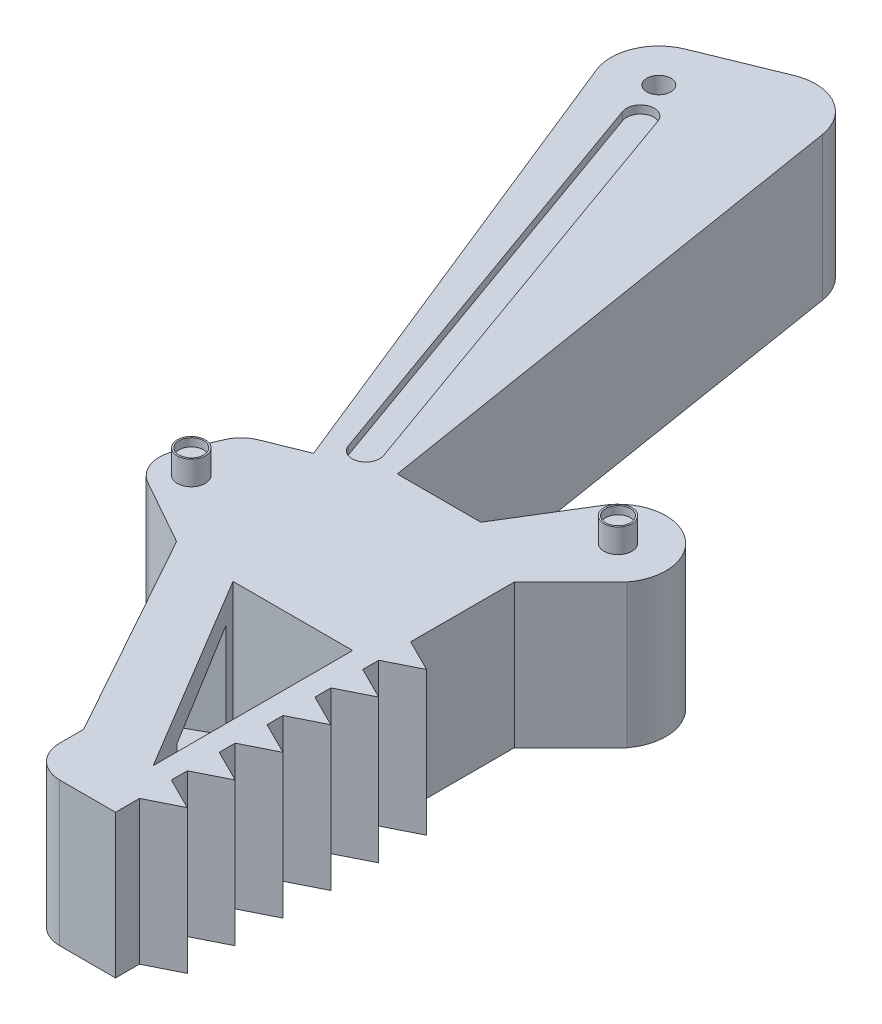
from build123d import *

# Parameters (mm, degrees)
BOSS_EXTRUDE1_DEPTH = 9
FILLET1_R           = 6
FILLET2_R           = 4
BOSS_EXTRUDE2_DEPTH = 18
LPATTERN1_COUNT     = 6
LPATTERN1_PITCH     = 6
CUT_EXTRUDE1_DEPTH  = 19
CUT_EXTRUDE2_DEPTH  = 8
SKETCH5_R           = 1.5
CUT_EXTRUDE3_DEPTH  = 19
SKETCH6_R           = 1.75
BOSS_EXTRUDE3_DEPTH = 3
SKETCH7_R           = 1.55
CUT_EXTRUDE4_DEPTH  = 1
SKETCH8_R           = 1.55
CUT_EXTRUDE5_DEPTH  = 1
CUT_EXTRUDE7_DEPTH  = 1


with BuildPart() as part:
    # Sketch1 → Boss-Extrude1 (new body, symmetric)
    with BuildSketch(Plane(origin=(0, 0, 0), x_dir=(1, 0, 0), z_dir=(0, 1, 0))):
        with BuildLine():
            Line((-12.33246069, -71), (-19.816764537, -74.012394232))
            Line((-19.816764537, -74.012394232), (-26.247607485, -76.600775811))
            Line((-26.247607485, -76.600775811), (-30.167039554, -85.800669955))
            Line((-30.167039554, -85.800669955), (-18.831549927, -92.165155394))
            Line((-18.831549927, -92.165155394), (-4.262261991, -118.389873678))
            Line((-4.262261991, -118.389873678), (-4.262261991, -125.389873678))
            Line((-4.262261991, -125.389873678), (6.737738009, -125.389873678))
            Line((6.737738009, -125.389873678), (6.737738009, -75.389873678))
            Line((6.737738009, -75.389873678), (13.808805821, -68.318805866))
            ThreePointArc((13.808805821, -68.318805866), (12.667091661, -59.910685459), (4.258971254, -61.052399619))
            Line((4.258971254, -61.052399619), (-1.849045895, -71))
            Line((-1.849045895, -71), (-12.33246069, -71))
        make_face()
        Polygon((-12.33246069, -71), (-19.816764537, -74.012394232), (-45.953718322, -9.075042525), (-23.735626524, 0), align=None)
    extrude(amount=BOSS_EXTRUDE1_DEPTH, both=True)

    # Fillet1
    fillet1_edges = [part.edges().sort_by_distance(p)[0] for p in [
        (-45.953718322, 0, 9.075042525),
        (-23.735626524, 0, 0),
    ]]
    fillet(fillet1_edges, radius=FILLET1_R)

    # Fillet2
    fillet2_edges = [part.edges().sort_by_distance(p)[0] for p in [
        (-4.262261991, 0, 125.389873678),
        (-30.167039554, 0, 85.800669955),
        (-26.247607485, 0, 76.600775811),
    ]]
    fillet(fillet2_edges, radius=FILLET2_R)

    # Sketch2 → Boss-Extrude2 (add)
    with BuildSketch(Plane(origin=(0, 9, 0), x_dir=(1, 0, 0), z_dir=(0, 1, 0))):
        Polygon((6.737738009, -118.389873678), (6.737738009, -122.389873678), (10.737738009, -120.389873678), align=None)
    boss_extrude2 = extrude(amount=-BOSS_EXTRUDE2_DEPTH)

    # LPattern1: Boss-Extrude2 ×6
    with Locations(*[(0, 0, -i * LPATTERN1_PITCH) for i in range(1, LPATTERN1_COUNT)]):
        add(boss_extrude2)

    # Sketch3 → Cut-Extrude1 (cut, through all)
    with BuildSketch(Plane(origin=(0, 9, 0), x_dir=(1, 0, 0), z_dir=(0, 1, 0))):
        Polygon((4.039450666, -92.96261283), (-10.960549334, -92.96261283), (4.039450666, -117.96261283), align=None)
    extrude(amount=-CUT_EXTRUDE1_DEPTH, mode=Mode.SUBTRACT)

    # Sketch4 → Cut-Extrude2 (cut)
    with BuildSketch(Plane(origin=(-53.516863555, 0, 29.731590864), x_dir=(0.485642931, 0, 0.874157276), z_dir=(-0.874157276, 0, 0.485642931))):
        Polygon((78.421432088, 6), (78.421432088, -6), (96.421432088, -5.431048589), (96.421432088, 5.431048589), align=None)
    extrude(amount=-CUT_EXTRUDE2_DEPTH, mode=Mode.SUBTRACT)

    # Sketch5 → Cut-Extrude3 (cut, through all)
    with BuildSketch(Plane(origin=(0, 9, 0), x_dir=(1, 0, 0), z_dir=(0, 1, 0))):
        with Locations((-38.158783011, -12.372383774)):
            Circle(SKETCH5_R)
    extrude(amount=-CUT_EXTRUDE3_DEPTH, mode=Mode.SUBTRACT)

    # Sketch6 → Boss-Extrude3 (add)
    with BuildSketch(Plane(origin=(0, 9, 0), x_dir=(1, 0, 0), z_dir=(0, 1, 0))):
        with Locations((-25.081319154, -84.068763596)):
            Circle(SKETCH6_R)
        with Locations((9.033888537, -64.685602742)):
            Circle(SKETCH6_R)
    boss_extrude3 = extrude(amount=BOSS_EXTRUDE3_DEPTH)

    # Sketch7 → Cut-Extrude4 (cut)
    with BuildSketch(Plane(origin=(0, 12, 0), x_dir=(1, 0, 0), z_dir=(0, 1, 0))):
        with Locations((-25.081319154, -84.068763596)):
            Circle(SKETCH7_R)
    cut_extrude4 = extrude(amount=-CUT_EXTRUDE4_DEPTH, mode=Mode.SUBTRACT)

    # Sketch8 → Cut-Extrude5 (cut)
    with BuildSketch(Plane(origin=(0, 12, 0), x_dir=(1, 0, 0), z_dir=(0, 1, 0))):
        with Locations((9.033888537, -64.685602742)):
            Circle(SKETCH8_R)
    cut_extrude5 = extrude(amount=-CUT_EXTRUDE5_DEPTH, mode=Mode.SUBTRACT)

    # Sketch9 → Cut-Extrude7 (cut)
    with BuildSketch(Plane(origin=(0, 9, 0), x_dir=(1, 0, 0), z_dir=(0, 1, 0))):
        with BuildLine():
            Line((-34.306763605, -16.326309504), (-15.181058532, -69.865166146))
            ThreePointArc((-15.181058532, -69.865166146), (-16.229593753, -72.079184588), (-18.443612196, -71.030649368))
            Line((-18.443612196, -71.030649368), (-37.569317268, -17.491792726))
            ThreePointArc((-37.569317268, -17.491792726), (-36.520782048, -15.277774283), (-34.306763605, -16.326309504))
        make_face()
    cut_extrude7 = extrude(amount=-CUT_EXTRUDE7_DEPTH, mode=Mode.SUBTRACT)

    # Mirror1: Boss-Extrude3, Cut-Extrude4, Cut-Extrude5, Cut-Extrude7 across plane
    add(boss_extrude3.mirror(Plane.ZX))
    add(cut_extrude4.mirror(Plane.ZX), mode=Mode.SUBTRACT)
    add(cut_extrude5.mirror(Plane.ZX), mode=Mode.SUBTRACT)
    add(cut_extrude7.mirror(Plane.ZX), mode=Mode.SUBTRACT)


solid = part.part
